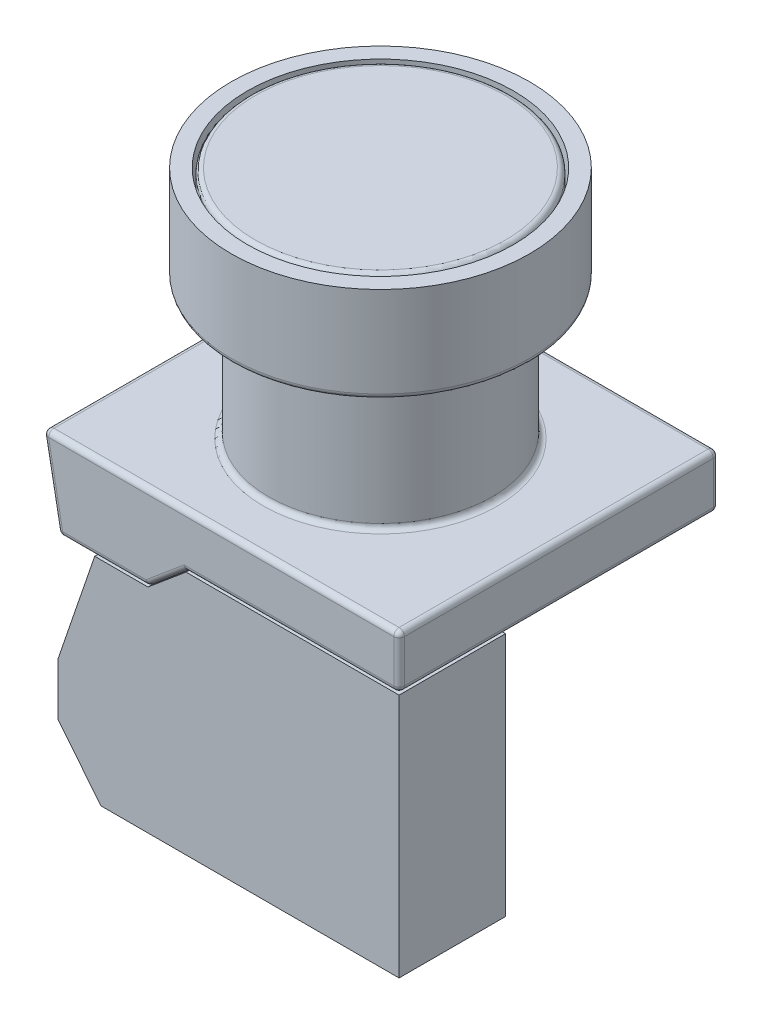
from build123d import *

# Parameters (mm, degrees)
BOSS_EXTRUDE1_DEPTH = 10
BOSS_EXTRUDE2_DEPTH = 30
SKETCH4_R           = 10.5
BOSS_EXTRUDE3_DEPTH = 13
SKETCH5_R           = 14
BOSS_EXTRUDE4_DEPTH = 9
SKETCH6_R           = 12.5
CUT_EXTRUDE1_DEPTH  = 5
SKETCH7_R           = 12.25
BOSS_EXTRUDE5_DEPTH = 5
FILLET1_R           = 0.5
FILLET2_R           = 0.5


with BuildPart() as part:
    # Sketch1 → Boss-Extrude1 (new body)
    with BuildSketch(Plane.XY):
        Polygon((0, 0), (-4, 5), (-4, 10), (-0.576361612, 20), (4.423638388, 20), (8, 23), (28, 23), (28, 0), align=None)
    extrude(amount=BOSS_EXTRUDE1_DEPTH)


with BuildPart() as body_2:
    # Sketch3 → Boss-Extrude2 (new body)
    with BuildSketch(Plane.XY.offset(10)):
        Polygon((28, 23), (8, 23), (4.423638388, 20), (-0.576361612, 20), (-4, 20), (-5.5, 28), (28, 28), align=None)
    extrude(amount=-BOSS_EXTRUDE2_DEPTH)

    # Sketch4 → Boss-Extrude3 (add)
    with BuildSketch(Plane(origin=(0, 28, 0), x_dir=(1, 0, 0), z_dir=(0, 1, 0))):
        with Locations((11.25, 5)):
            Circle(SKETCH4_R)
    extrude(amount=BOSS_EXTRUDE3_DEPTH)

    # Sketch5 → Boss-Extrude4 (add)
    with BuildSketch(Plane(origin=(0, 41, 0), x_dir=(1, 0, 0), z_dir=(0, 1, 0))):
        with Locations((11.25, 5)):
            Circle(SKETCH5_R)
    extrude(amount=BOSS_EXTRUDE4_DEPTH)

    # Sketch6 → Cut-Extrude1 (cut)
    with BuildSketch(Plane(origin=(0, 50, 0), x_dir=(1, 0, 0), z_dir=(0, 1, 0))):
        with Locations((11.25, 5)):
            Circle(SKETCH6_R)
    extrude(amount=-CUT_EXTRUDE1_DEPTH, mode=Mode.SUBTRACT)

    # Sketch7 → Boss-Extrude5 (add)
    with BuildSketch(Plane(origin=(0, 45, 0), x_dir=(1, 0, 0), z_dir=(0, 1, 0))):
        with Locations((11.25, 5)):
            Circle(SKETCH7_R)
    extrude(amount=BOSS_EXTRUDE5_DEPTH)

    # Fillet1
    fillet1_edges = [body_2.edges().sort_by_distance(p)[0] for p in [
        (-1, 50, -5),
    ]]
    fillet(fillet1_edges, radius=FILLET1_R)

    # Fillet2
    fillet2_edges = [body_2.edges().sort_by_distance(p)[0] for p in [
        (-4.75, 24, -20),
        (28, 23, -5),
        (4.423638388, 20, -5),
        (-4, 20, -5),
        (-5.5, 28, -5),
        (28, 28, -5),
        (0.211819194, 20, -20),
        (6.211819194, 21.5, -20),
        (18, 23, -20),
        (0.75, 28, -5),
        (0.75, 41, -5),
        (-2.75, 41, -5),
        (28, 25.5, -20),
        (18, 23, 10),
        (11.25, 28, -20),
        (6.211819194, 21.5, 10),
        (0.211819194, 20, 10),
        (-4.75, 24, 10),
        (11.25, 28, 10),
        (28, 25.5, 10),
    ]]
    fillet(fillet2_edges, radius=FILLET2_R)


solid = Compound([part.part, body_2.part])
